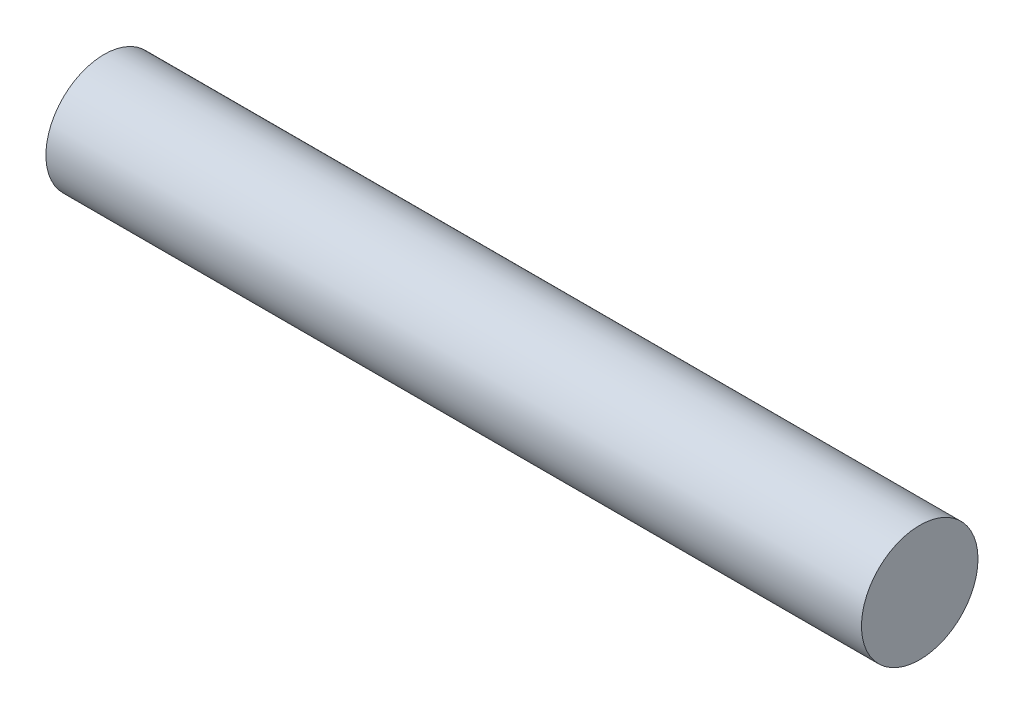
from build123d import *

# Parameters (mm, degrees)
SKETCH1_R           = 19.05
BOSS_EXTRUDE1_DEPTH = 133.35


with BuildPart() as part:
    # Sketch1 → Boss-Extrude1 (new body, symmetric)
    with BuildSketch(Plane(origin=(0, 0, 0), x_dir=(0, 0, -1), z_dir=(1, 0, 0))):
        Circle(SKETCH1_R)
    extrude(amount=BOSS_EXTRUDE1_DEPTH, both=True)


solid = part.part
